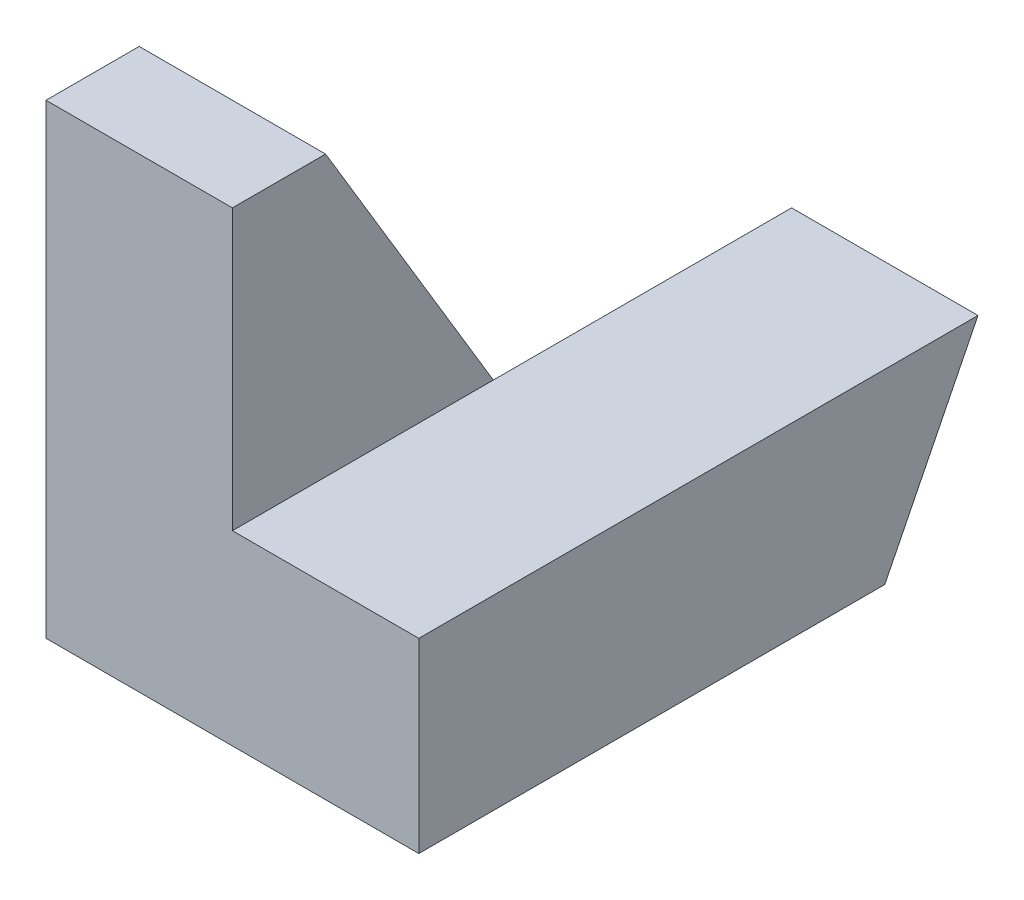
from build123d import *

# Parameters (mm, degrees)
BOSS_EXTRUDE1_DEPTH = 2
BOSS_EXTRUDE2_DEPTH = 2


with BuildPart() as part:
    # Sketch1 → Boss-Extrude1 (new body)
    with BuildSketch(Plane(origin=(0, 0, 0), x_dir=(0, 0, -1), z_dir=(1, 0, 0))):
        Polygon((0, 0), (0, 5), (1, 5), (4, 0), align=None)
    extrude(amount=BOSS_EXTRUDE1_DEPTH)

    # Sketch2 → Boss-Extrude2 (add)
    with BuildSketch(Plane(origin=(2, 0, 0), x_dir=(0, 0, -1), z_dir=(1, 0, 0))):
        Polygon((0, 0), (5, 0), (6, 2), (0, 2), align=None)
    extrude(amount=BOSS_EXTRUDE2_DEPTH)


solid = part.part
